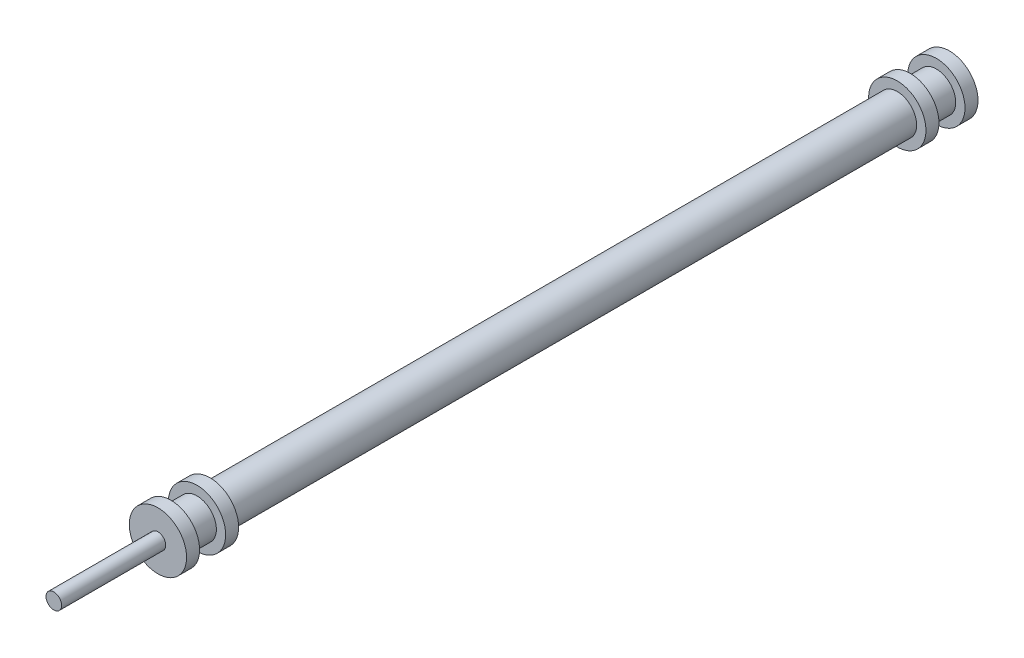
from build123d import *

# Parameters (mm, degrees)
SKETCH1_R           = 3.725
BOSS_EXTRUDE1_DEPTH = 132
SKETCH3_R           = 5.5
BOSS_EXTRUDE3_DEPTH = 2.5
SKETCH4_R           = 3.725
BOSS_EXTRUDE4_DEPTH = 5
SKETCH5_R           = 5.5
BOSS_EXTRUDE5_DEPTH = 2.5
SKETCH6_R           = 1.5
BOSS_EXTRUDE6_DEPTH = 20


with BuildPart() as part:
    # Sketch1 → Boss-Extrude1 (new body)
    with BuildSketch(Plane.XY):
        Circle(SKETCH1_R)
    extrude(amount=BOSS_EXTRUDE1_DEPTH)

    # Sketch3 → Boss-Extrude3 (add)
    with BuildSketch(Plane.XY.offset(132)):
        Circle(SKETCH3_R)
    boss_extrude3 = extrude(amount=BOSS_EXTRUDE3_DEPTH)

    # Sketch4 → Boss-Extrude4 (add)
    with BuildSketch(Plane.XY.offset(134.5)):
        Circle(SKETCH4_R)
    boss_extrude4 = extrude(amount=BOSS_EXTRUDE4_DEPTH)

    # Sketch5 → Boss-Extrude5 (add)
    with BuildSketch(Plane.XY.offset(139.5)):
        Circle(SKETCH5_R)
    boss_extrude5 = extrude(amount=BOSS_EXTRUDE5_DEPTH)

    # Mirror2: Boss-Extrude3, Boss-Extrude4, Boss-Extrude5 across plane
    add(boss_extrude3.mirror(Plane.XY.offset(66)))
    add(boss_extrude4.mirror(Plane.XY.offset(66)))
    add(boss_extrude5.mirror(Plane.XY.offset(66)))

    # Sketch6 → Boss-Extrude6 (add)
    with BuildSketch(Plane.XY.offset(142)):
        Circle(SKETCH6_R)
    extrude(amount=BOSS_EXTRUDE6_DEPTH)


solid = part.part
